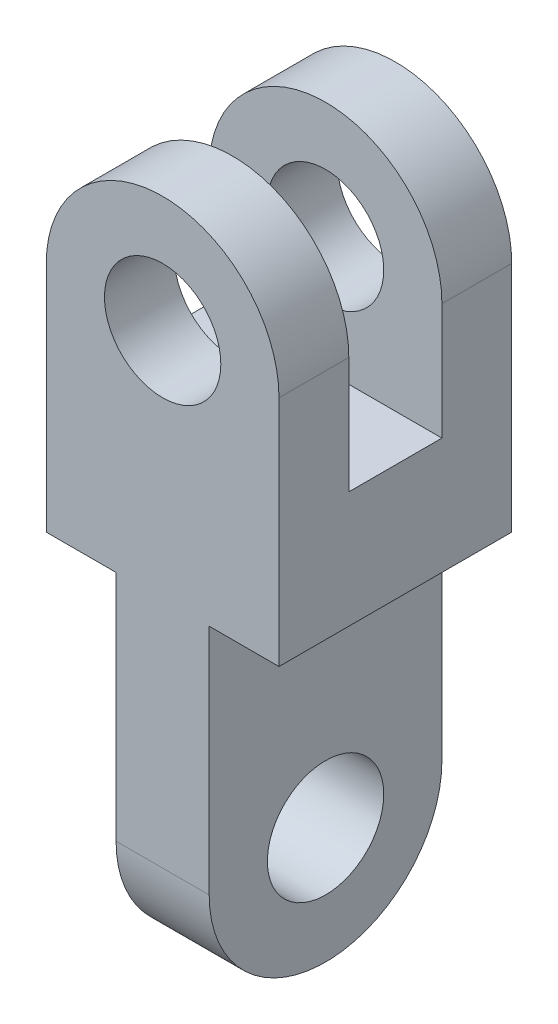
from build123d import *

# Parameters (mm, degrees)
CROQUIS2_R              = 25
SALIENTE_EXTRUIR1_DEPTH = 100
CORTAR_EXTRUIR1_DEPTH   = 100
CROQUIS4_R              = 25
CORTAR_EXTRUIR2_DEPTH   = 100
CROQUIS5_W              = 40
CROQUIS5_H              = 50
CORTAR_EXTRUIR3_DEPTH   = 101


with BuildPart() as part:
    # Croquis2 → Saliente-Extruir1 (new body)
    with BuildSketch(Plane.XY):
        with BuildLine():
            Line((0, 0), (40, 0))
            Line((40, 0), (40, 150))
            Line((40, 150), (70, 150))
            Line((70, 150), (70, 250))
            ThreePointArc((70, 250), (20, 300), (-30, 250))
            Line((-30, 250), (-30, 150))
            Line((-30, 150), (0, 150))
            Line((0, 150), (0, 0))
        make_face()
        with Locations((20, 250)):
            Circle(CROQUIS2_R, mode=Mode.SUBTRACT)
    extrude(amount=SALIENTE_EXTRUIR1_DEPTH)

    # Croquis3 → Cortar-Extruir1 (cut)
    with BuildSketch(Plane(origin=(40, 0, 0), x_dir=(0, 0, -1), z_dir=(1, 0, 0))):
        with BuildLine():
            ThreePointArc((-50, 0), (-85.355339059, 14.644660941), (-100, 50))
            Line((-100, 50), (-100, 0))
            Line((-100, 0), (-50, 0))
        make_face()
        with BuildLine():
            ThreePointArc((0, 50), (-14.644660941, 14.644660941), (-50, 0))
            Line((-50, 0), (0, 0))
            Line((0, 0), (0, 50))
        make_face()
    extrude(amount=-CORTAR_EXTRUIR1_DEPTH, mode=Mode.SUBTRACT)

    # Croquis4 → Cortar-Extruir2 (cut)
    with BuildSketch(Plane(origin=(40, 0, 0), x_dir=(0, 0, -1), z_dir=(1, 0, 0))):
        with Locations((-50, 50)):
            Circle(CROQUIS4_R)
    extrude(amount=-CORTAR_EXTRUIR2_DEPTH, mode=Mode.SUBTRACT)

    # Croquis5 → Cortar-Extruir3 (cut, through all)
    with BuildSketch(Plane(origin=(70, 0, 0), x_dir=(0, 0, -1), z_dir=(1, 0, 0))):
        with Locations((-50, 275)):
            Rectangle(CROQUIS5_W, CROQUIS5_H)
        with Locations((-50, 225)):
            Rectangle(CROQUIS5_W, CROQUIS5_H)
    extrude(amount=-CORTAR_EXTRUIR3_DEPTH, mode=Mode.SUBTRACT)


solid = part.part
